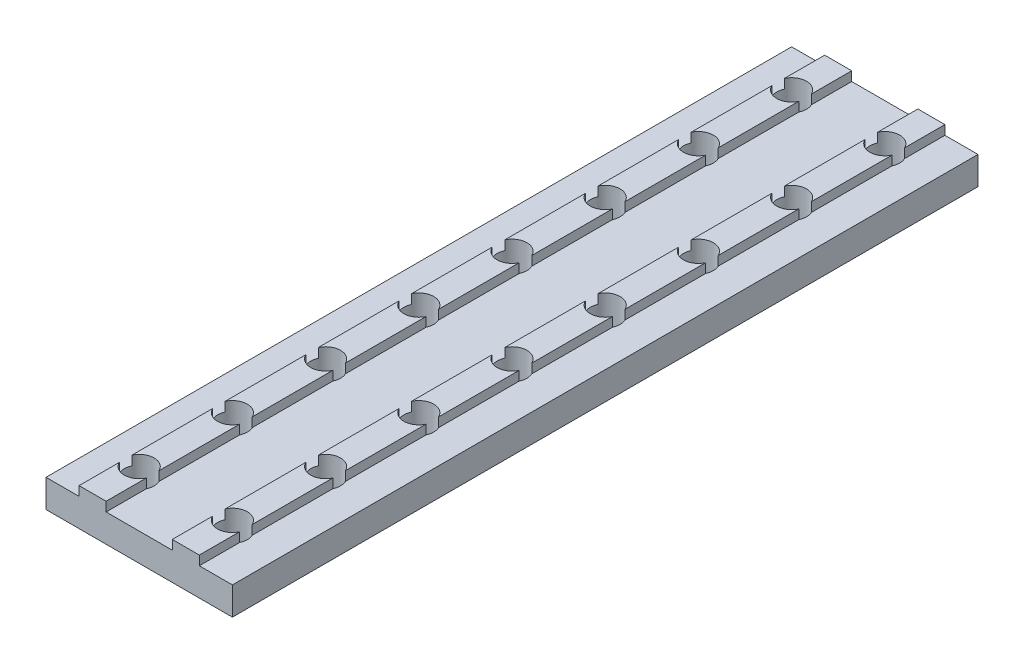
from build123d import *

# Parameters (mm, degrees)
MAIN_DEPTH                      = 20
ESQUISSE2_R                     = 1.6
TOPHOLE_DEPTH                   = 22
R_P_TITION_LIN_AIRE1_COUNT      = 4
R_P_TITION_LIN_AIRE1_PITCH      = 20
R_P_TITION_LIN_AIRE1_COUNT_DIR2 = 2
R_P_TITION_LIN_AIRE1_PITCH_DIR2 = 10


with BuildPart() as part:
    # Esquisse1 → Main (new body)
    with BuildSketch(Plane.XY):
        Polygon((-5, 0), (-5, 3), (-1.45, 3), (-1.45, 4), (1.45, 4), (1.45, 3), (5, 3), (5, 0), align=None)
    main = extrude(amount=MAIN_DEPTH)

    # Esquisse2 → TopHole (cut, through all)
    with BuildSketch(Plane(origin=(0, 4, 0), x_dir=(1, 0, 0), z_dir=(0, 1, 0))):
        with Locations((0, -5)):
            Circle(ESQUISSE2_R)
        with Locations((0, -15)):
            Circle(ESQUISSE2_R)
    tophole = extrude(amount=-TOPHOLE_DEPTH, mode=Mode.SUBTRACT)

    # Répétition linéaire1: Main, TopHole 4 × 2
    with Locations(*[(-j * R_P_TITION_LIN_AIRE1_PITCH_DIR2, 0, i * R_P_TITION_LIN_AIRE1_PITCH) for i in range(R_P_TITION_LIN_AIRE1_COUNT) for j in range(R_P_TITION_LIN_AIRE1_COUNT_DIR2) if (i, j) != (0, 0)]):
        add(main)
        add(tophole, mode=Mode.SUBTRACT)


solid = part.part
